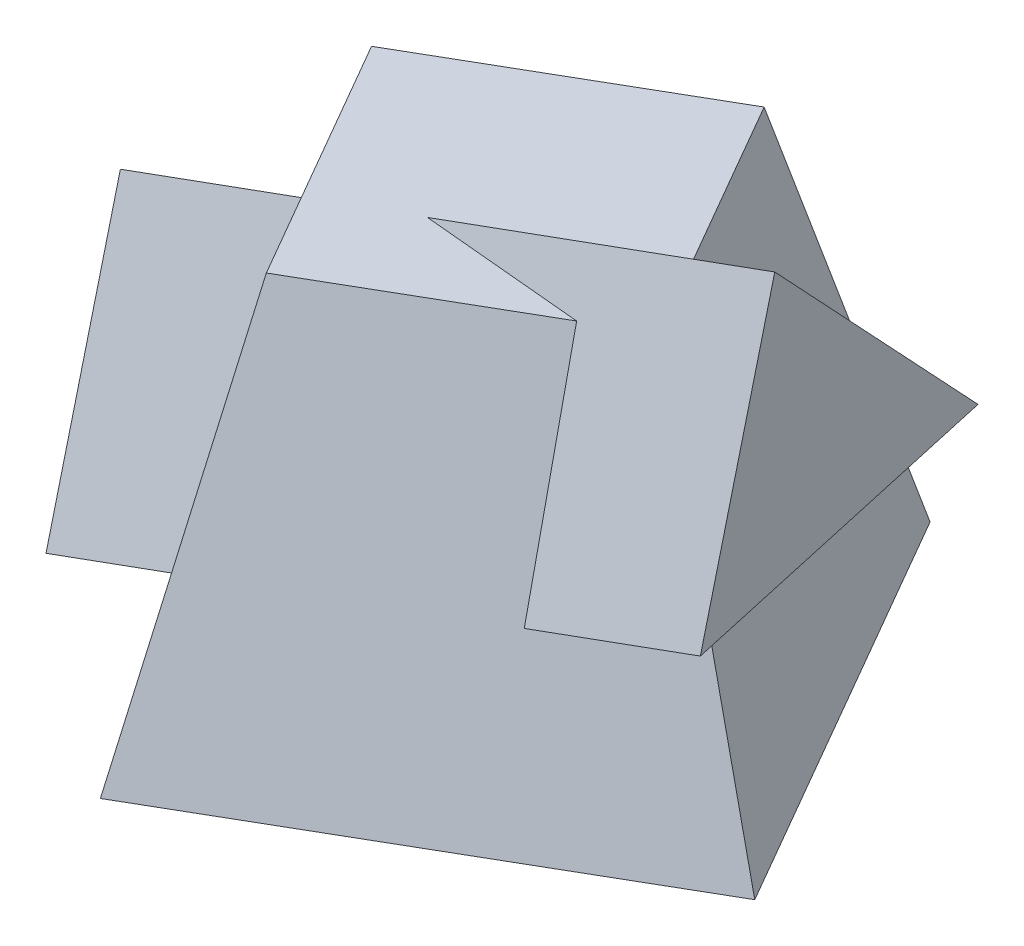
from build123d import *

# Parameters (mm, degrees)
TRIANGULAR_PRISM_DEPTH = 170
SKETCH5_W              = 20.831302692
SKETCH5_H              = 63.48520277
SKETCH5_W_2            = 25.650693989
SKETCH5_H_2            = 114.24619151
CUT_EXTRUDE1_DEPTH     = 100


with BuildPart() as part:
    # Sketch2 → Pyramid section 0
    with BuildSketch(Plane(origin=(0, 85, 0), x_dir=(-1, 0, 0), z_dir=(0, 1, 0))):
        Polygon((59.282032303, 57.320508076), (7.320508076, 27.320508076), (-22.679491924, 79.282032303), (29.282032303, 109.282032303), align=None)
    # Sketch1 → Pyramid section 1
    with BuildSketch(Plane(origin=(0, 0, 0), x_dir=(1, 0, 0), z_dir=(0, 1, 0))):
        Polygon((0, 0), (-86.602540378, -50), (-36.602540378, -136.602540378), (50, -86.602540378), align=None)
    loft()

    # Sketch4 → Triangular Prism (add)
    with BuildSketch(Plane(origin=(-76.471967598, -27.833519961, 0), x_dir=(0, 0, -1), z_dir=(0.939692621, 0.342020143, 0))):
        Polygon((-97.955549577, 29.619813273), (-40, 45.148955979), (-82.426406871, 87.57536285), align=None)
    extrude(amount=TRIANGULAR_PRISM_DEPTH)

    # Sketch5 → Cut-Extrude1 (cut)
    with BuildSketch(Plane.XY):
        with Locations((-97.018191724, 31.742601385)):
            Rectangle(SKETCH5_W, SKETCH5_H)
        with Locations((62.825346995, 57.123095755)):
            Rectangle(SKETCH5_W_2, SKETCH5_H_2)
    extrude(amount=CUT_EXTRUDE1_DEPTH, mode=Mode.SUBTRACT)


solid = part.part
